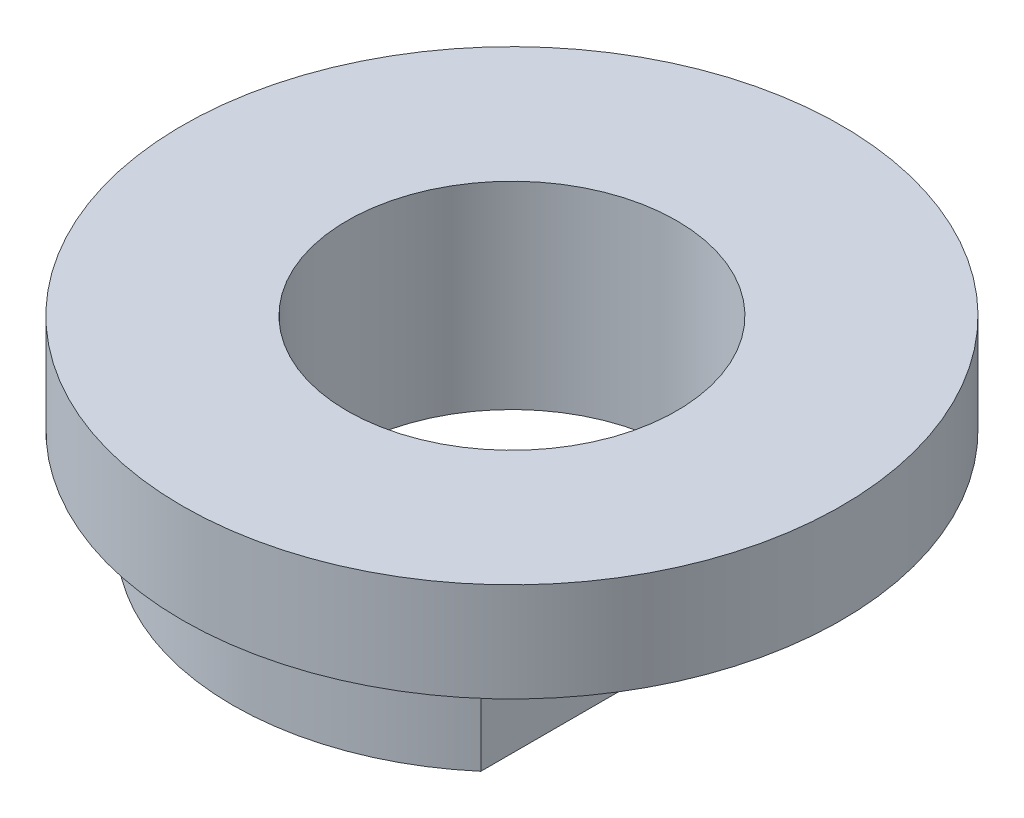
from build123d import *

# Parameters (mm, degrees)
SKETCH1_R           = 5
BOSS_EXTRUDE1_DEPTH = 3
SKETCH2_R           = 10
SKETCH2_R_2         = 5
BOSS_EXTRUDE2_DEPTH = 3


with BuildPart() as part:
    # Sketch1 → Boss-Extrude1 (new body)
    with BuildSketch(Plane(origin=(0, 0, 0), x_dir=(1, 0, 0), z_dir=(0, 1, 0))):
        with BuildLine():
            Line((-281.53939526, 229.203780512), (-281.53939526, 216.403780512))
            ThreePointArc((-281.53939526, 216.403780512), (-276.03939526, 214.375557893), (-270.53939526, 216.403780512))
            Line((-270.53939526, 216.403780512), (-270.53939526, 229.203780512))
            ThreePointArc((-270.53939526, 229.203780512), (-276.03939526, 231.252855213), (-281.53939526, 229.203780512))
        make_face()
        with Locations((-276.03939526, 222.846937384)):
            Circle(SKETCH1_R, mode=Mode.SUBTRACT)
    extrude(amount=BOSS_EXTRUDE1_DEPTH)

    # Sketch2 → Boss-Extrude2 (add)
    with BuildSketch(Plane(origin=(0, 3, 0), x_dir=(1, 0, 0), z_dir=(0, 1, 0))):
        with Locations((-276.03939526, 222.846937384)):
            Circle(SKETCH2_R)
        with Locations((-276.03939526, 222.846937384)):
            Circle(SKETCH2_R_2, mode=Mode.SUBTRACT)
    extrude(amount=BOSS_EXTRUDE2_DEPTH)


solid = part.part
